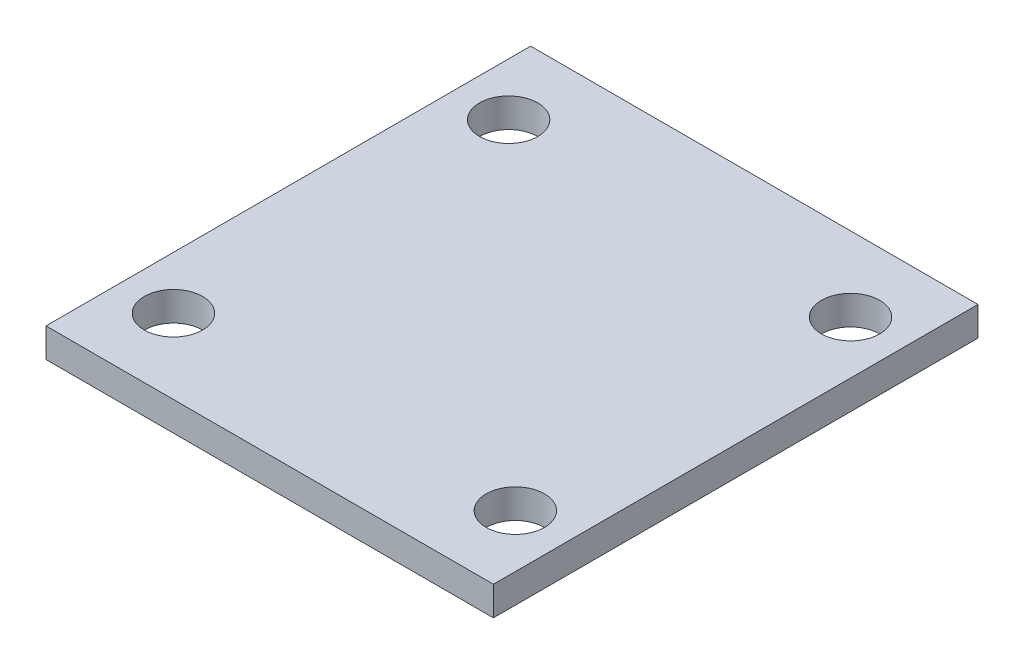
from build123d import *

# Parameters (mm, degrees)
SKETCH1_W           = 30.7
SKETCH1_H           = 33.25
SKETCH1_R           = 2
BOSS_EXTRUDE1_DEPTH = 2


with BuildPart() as part:
    # Sketch1 → Boss-Extrude1 (new body)
    with BuildSketch(Plane(origin=(0, 0, 0), x_dir=(1, 0, 0), z_dir=(0, 1, 0))):
        with Locations((15.35, 16.625)):
            Rectangle(SKETCH1_W, SKETCH1_H)
        with Locations((3.62, 28.125)):
            Circle(SKETCH1_R, mode=Mode.SUBTRACT)
        with Locations((27.08, 28.125)):
            Circle(SKETCH1_R, mode=Mode.SUBTRACT)
        with Locations((27.08, 5.125)):
            Circle(SKETCH1_R, mode=Mode.SUBTRACT)
        with Locations((3.62, 5.125)):
            Circle(SKETCH1_R, mode=Mode.SUBTRACT)
    extrude(amount=BOSS_EXTRUDE1_DEPTH)


solid = part.part
